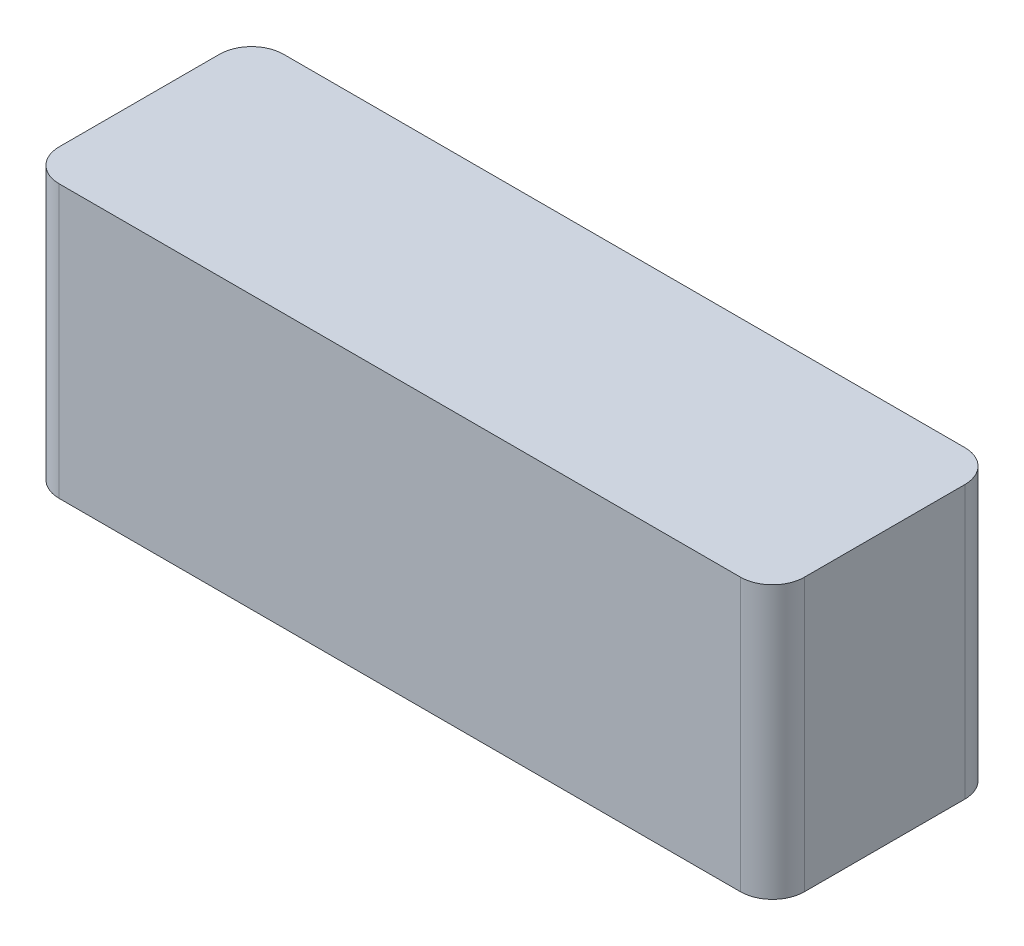
from build123d import *

# Parameters (mm, degrees)
SKETCH_1_W      = 186
SKETCH_1_H      = 68
EXTRUDE_1_DEPTH = 56
FILLET_1_R      = 8


with BuildPart() as part:
    # 草图1 → 凸台-拉伸1 (new body)
    with BuildSketch(Plane.XY):
        Rectangle(SKETCH_1_W, SKETCH_1_H)
    extrude(amount=EXTRUDE_1_DEPTH)

    # 圆角1
    fillet_1_edges = [part.edges().sort_by_distance(p)[0] for p in [
        (93, 0, 56),
        (-93, 0, 56),
        (93, 0, 0),
        (-93, 0, 0),
    ]]
    fillet(fillet_1_edges, radius=FILLET_1_R)


solid = part.part
